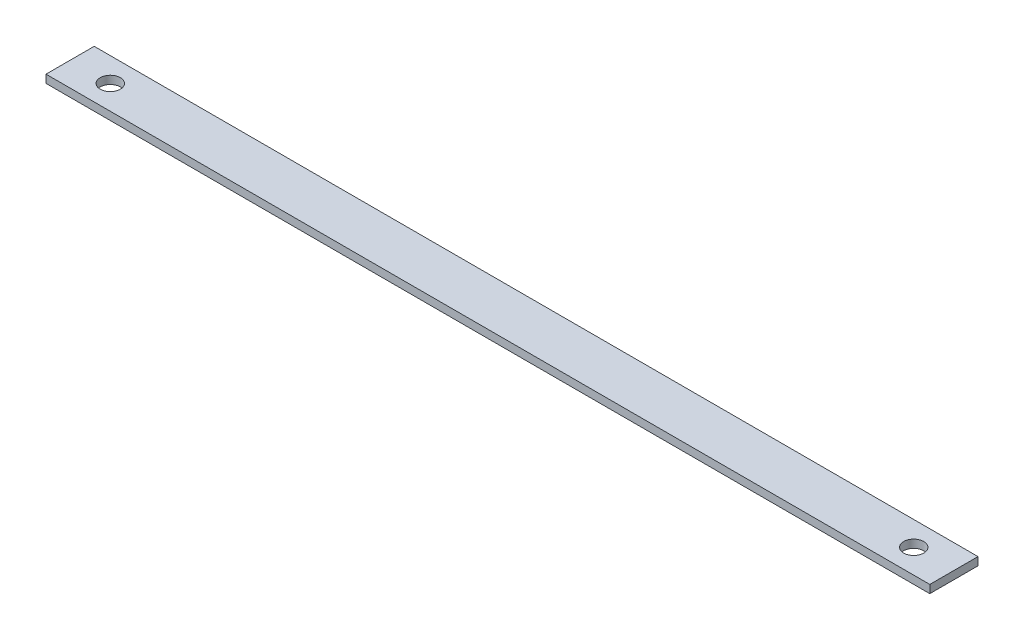
from build123d import *

# Parameters (mm, degrees)
SKETCH1_W                 = 220
SKETCH1_H                 = 12
BOSS_EXTRUDE1_DEPTH       = 2
F_5_0MM_DOWEL_HOLE1_D     = 5
F_5_0MM_DOWEL_HOLE1_DEPTH = 2


with BuildPart() as part:
    # Sketch1 → Boss-Extrude1 (new body)
    with BuildSketch(Plane(origin=(0, 0, 0), x_dir=(1, 0, 0), z_dir=(0, 1, 0))):
        Rectangle(SKETCH1_W, SKETCH1_H)
    extrude(amount=BOSS_EXTRUDE1_DEPTH)

    # Ø5.0mm Dowel Hole1
    with Locations(Plane(origin=(0, 2, 0), x_dir=(1, 0, 0), z_dir=(0, 1, 0))):
        with Locations((-100, 0), (100, 0)):
            Hole(F_5_0MM_DOWEL_HOLE1_D / 2, depth=F_5_0MM_DOWEL_HOLE1_DEPTH)


solid = part.part
